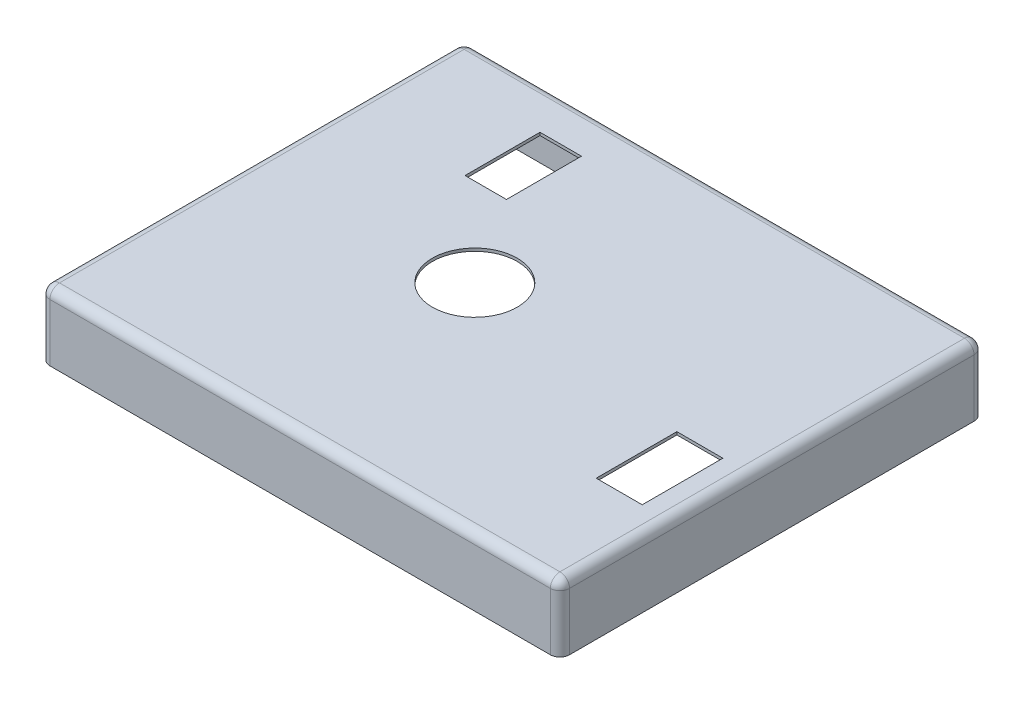
from build123d import *

# Parameters (mm, degrees)
BOSS_EXTRU_1_DEPTH      = 7
CONG_1_R                = 1
COQUE1_T                = -0.3
ENL_V_MAT_EXTRU_1_REACH = 9
ESQUISSE8_R             = 4.427961532
ENL_V_MAT_EXTRU_2_REACH = 9
ESQUISSE9_W             = 4.325203416
ESQUISSE9_H             = 7.820915767
ENL_V_MAT_EXTRU_3_REACH = 9
ESQUISSE10_W            = 4.799198311
ESQUISSE10_H            = 8.413409385


with BuildPart() as part:
    # Esquisse3 → Boss.-Extru.1 (new body)
    with BuildSketch(Plane(origin=(0, 0, 0), x_dir=(1, 0, 0), z_dir=(0, 1, 0))):
        with BuildLine():
            Line((-26.504477612, 19.954228856), (25.695522388, 19.954228856))
            ThreePointArc((25.695522388, 19.954228856), (26.402629169, 19.661335637), (26.695522388, 18.954228856))
            Line((26.695522388, 18.954228856), (26.695522388, -23.245771144))
            ThreePointArc((26.695522388, -23.245771144), (26.402629169, -23.952877925), (25.695522388, -24.245771144))
            Line((25.695522388, -24.245771144), (-26.504477612, -24.245771144))
            ThreePointArc((-26.504477612, -24.245771144), (-27.211584393, -23.952877925), (-27.504477612, -23.245771144))
            Line((-27.504477612, -23.245771144), (-27.504477612, 18.954228856))
            ThreePointArc((-27.504477612, 18.954228856), (-27.211584393, 19.661335637), (-26.504477612, 19.954228856))
        make_face()
    extrude(amount=BOSS_EXTRU_1_DEPTH)

    # Congé1
    cong_1_edges = [part.edges().sort_by_distance(p)[0] for p in [
        (26.402629169, 7, -19.661335637),
        (26.695522388, 7, 2.145771144),
        (26.402629169, 7, 23.952877925),
        (-0.404477612, 7, 24.245771144),
        (-27.211584393, 7, 23.952877925),
        (-27.504477612, 7, 2.145771144),
        (-27.211584393, 7, -19.661335637),
        (-0.404477612, 7, -19.954228856),
    ]]
    fillet(cong_1_edges, radius=CONG_1_R)

    # Coque1
    coque1_openings = [part.faces().sort_by_distance(p)[0] for p in [
        (-0.404477612, 0, 2.145771144),
    ]]
    offset(amount=COQUE1_T, openings=coque1_openings, kind=Kind.INTERSECTION)

    # Esquisse8 → Enlèv. mat.-Extru.1 (cut, up to next)
    with BuildSketch(Plane(origin=(0, 7, 0), x_dir=(1, 0, 0), z_dir=(0, 1, 0)), mode=Mode.PRIVATE) as enl_v_mat_extru_1_sk1:
        with Locations((-4.865513773, -1.564595223)):
            Circle(ESQUISSE8_R)
    enl_v_mat_extru_1_tool1 = extrude(enl_v_mat_extru_1_sk1.sketch, amount=-ENL_V_MAT_EXTRU_1_REACH, mode=Mode.PRIVATE) & part.part
    add(enl_v_mat_extru_1_tool1.solids().sort_by_distance((-4.865514, 7, 1.564595))[0], mode=Mode.SUBTRACT)

    # Esquisse9 → Enlèv. mat.-Extru.2 (cut, up to next)
    with BuildSketch(Plane(origin=(0, 7, 0), x_dir=(1, 0, 0), z_dir=(0, 1, 0)), mode=Mode.PRIVATE) as enl_v_mat_extru_2_sk1:
        with Locations((-12.89117049, 11.513635006)):
            Rectangle(ESQUISSE9_W, ESQUISSE9_H)
    enl_v_mat_extru_2_tool1 = extrude(enl_v_mat_extru_2_sk1.sketch, amount=-ENL_V_MAT_EXTRU_2_REACH, mode=Mode.PRIVATE) & part.part
    add(enl_v_mat_extru_2_tool1.solids().sort_by_distance((-12.89117, 7, -11.513635))[0], mode=Mode.SUBTRACT)

    # Esquisse10 → Enlèv. mat.-Extru.3 (cut, up to next)
    with BuildSketch(Plane(origin=(0, 7, 0), x_dir=(1, 0, 0), z_dir=(0, 1, 0)), mode=Mode.PRIVATE) as enl_v_mat_extru_3_sk1:
        with Locations((21.532708754, -8.690397391)):
            Rectangle(ESQUISSE10_W, ESQUISSE10_H)
    enl_v_mat_extru_3_tool1 = extrude(enl_v_mat_extru_3_sk1.sketch, amount=-ENL_V_MAT_EXTRU_3_REACH, mode=Mode.PRIVATE) & part.part
    add(enl_v_mat_extru_3_tool1.solids().sort_by_distance((21.532709, 7, 8.690397))[0], mode=Mode.SUBTRACT)


solid = part.part
